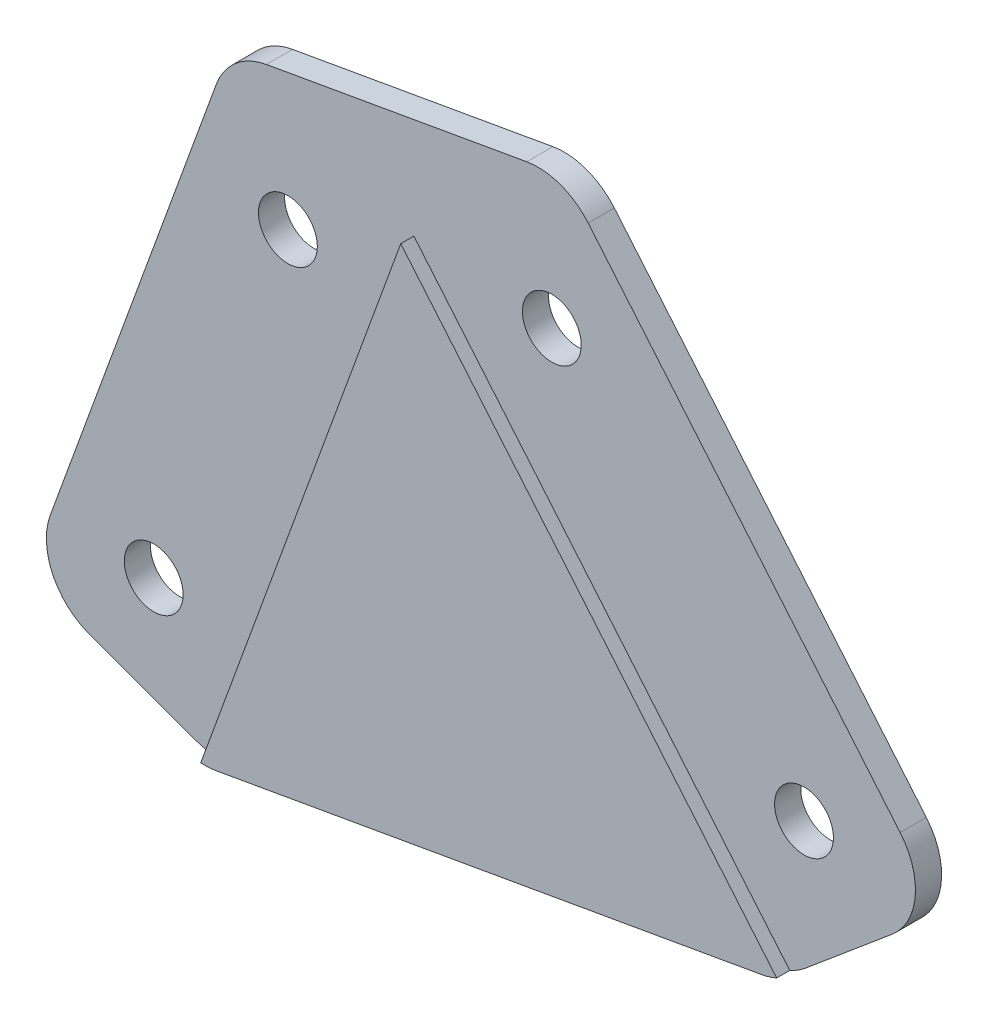
from build123d import *

# Parameters (mm, degrees)
EXTRUDE_1_DEPTH     = 3
SKETCH_2_R          = 2.25
CUT_EXTRUDE_1_DEPTH = 3
FILLET_1_R          = 5
CUT_EXTRUDE_2_DEPTH = 1


with BuildPart() as part:
    # ｽｹｯﾁ1 → ﾎﾞｽ - 押し出し1 (new body)
    with BuildSketch(Plane.XY):
        Polygon((173.531323483, 340.900859956), (144.605881047, 375.372859896), (133.1152144, 365.731045751), (119.019825089, 370.861347901), (103.628918639, 328.575179965), (117.724307951, 323.444877815), (162.040656836, 331.259045811), align=None)
        Polygon((144.605881047, 375.372859896), (133.1152144, 365.731045751), (119.019825089, 370.861347901), align=None)
    extrude(amount=EXTRUDE_1_DEPTH)

    # ｽｹｯﾁ2 → ｶｯﾄ - 押し出し1 (cut)
    with BuildSketch(Plane.XY.offset(3)):
        with Locations((113.24176437, 333.057723546)):
            Circle(SKETCH_2_R)
        with Locations((123.50236867, 361.24850217)):
            Circle(SKETCH_2_R)
        with Locations((143.681454796, 364.8066195)):
            Circle(SKETCH_2_R)
        with Locations((162.965083087, 341.825286207)):
            Circle(SKETCH_2_R)
    extrude(amount=-CUT_EXTRUDE_1_DEPTH, mode=Mode.SUBTRACT)

    # ﾌｨﾚｯﾄ1
    fillet_1_edges = [part.edges().sort_by_distance(p)[0] for p in [
        (173.531323483, 340.900859956, 1.5),
        (162.040656836, 331.259045811, 1.5),
        (117.724307951, 323.444877815, 1.5),
        (103.628918639, 328.575179965, 1.5),
        (119.019825089, 370.861347901, 1.5),
        (144.605881047, 375.372859896, 1.5),
    ]]
    fillet(fillet_1_edges, radius=FILLET_1_R)

    # ｽｹｯﾁ3 → ｶｯﾄ - 押し出し2 (cut)
    with BuildSketch(Plane.XY.offset(3)):
        Polygon((121.413966092, 377.439196246), (103.628918639, 328.575179965), (117.771292582, 323.427776808), (133.132579218, 365.632564976), (162.002354614, 331.22690643), (173.531323483, 340.900859956), (140.106367779, 380.735170998), (131.711632891, 373.691152049), align=None)
    extrude(amount=-CUT_EXTRUDE_2_DEPTH, mode=Mode.SUBTRACT)


solid = part.part
